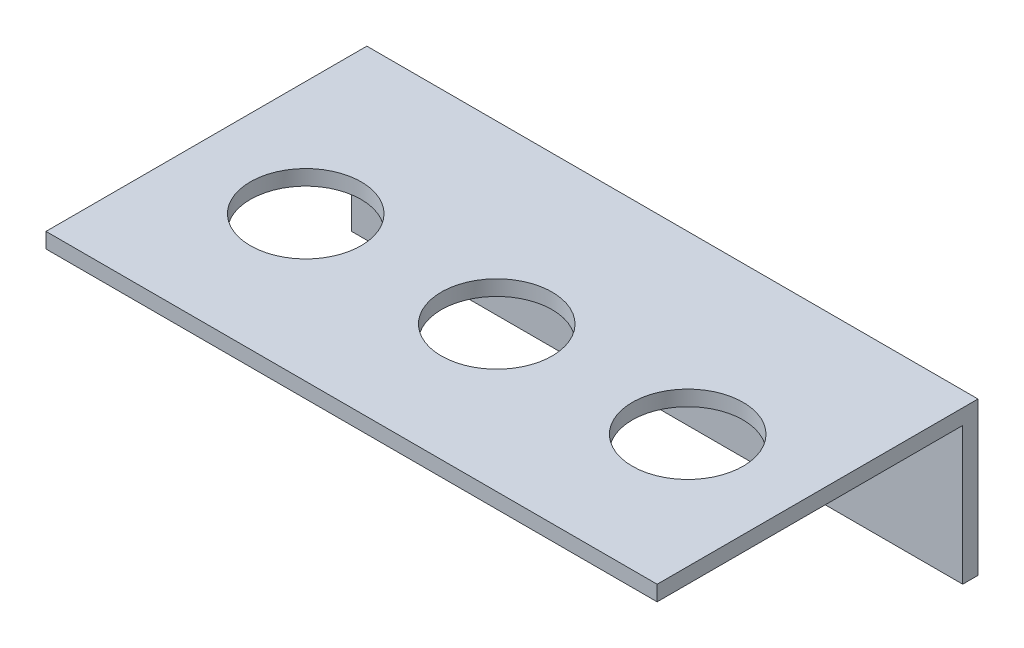
from build123d import *

# Parameters (mm, degrees)
IZIM1_W                     = 80
IZIM1_H                     = 20
Y_KSEKLIK_EKSTR_ZYON1_DEPTH = 42
BO_ALTMA1_T                 = -2
IZIM2_R                     = 7.25
KES_EKSTR_ZYON1_DEPTH       = 42


with BuildPart() as part:
    # Çizim1 → Yükseklik-Ekstrüzyon1 (new body)
    with BuildSketch(Plane.XY):
        Rectangle(IZIM1_W, IZIM1_H)
    extrude(amount=Y_KSEKLIK_EKSTR_ZYON1_DEPTH)

    # İç Boşaltma1
    bo_altma1_openings = [part.faces().sort_by_distance(p)[0] for p in [
        (0, 0, 42),
        (0, -10, 21),
        (-40, 0, 21),
        (40, 0, 21),
    ]]
    offset(amount=BO_ALTMA1_T, openings=bo_altma1_openings, kind=Kind.INTERSECTION)

    # Çizim2 → Kes-Ekstrüzyon1 (cut)
    with BuildSketch(Plane(origin=(0, 10, 0), x_dir=(1, 0, 0), z_dir=(0, 1, 0))):
        with Locations((0, -23)):
            Circle(IZIM2_R)
        with Locations((-25, -23)):
            Circle(IZIM2_R)
        with Locations((25, -23)):
            Circle(IZIM2_R)
    extrude(amount=-KES_EKSTR_ZYON1_DEPTH, mode=Mode.SUBTRACT)


solid = part.part
